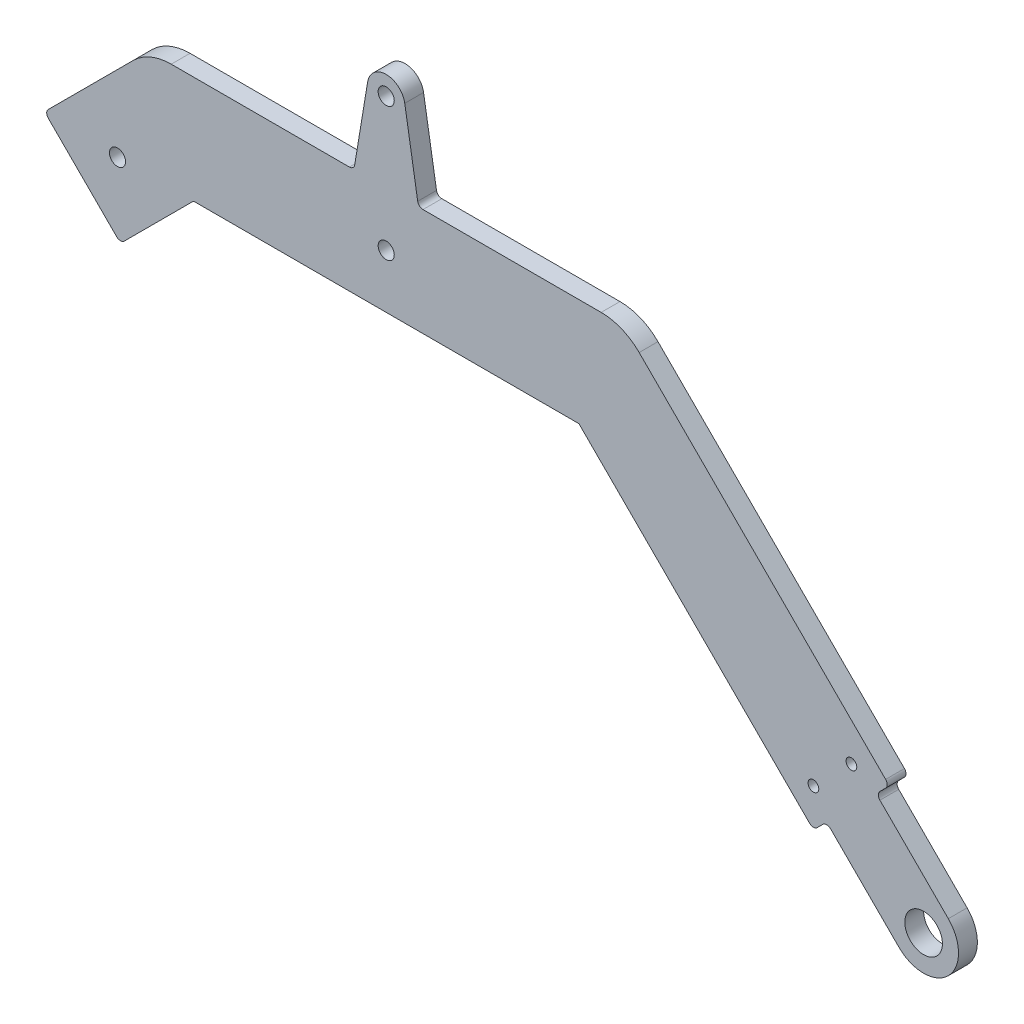
from build123d import *

# Parameters (mm, degrees)
SKETCH7_R           = 1.5
SKETCH7_R_2         = 3.5
SKETCH7_R_3         = 1
BOSS_EXTRUDE1_DEPTH = 3.5
FILLET8_R           = 10
FILLET14_R          = 1
FILLET15_R          = 1
FILLET16_R          = 1


with BuildPart() as part:
    # Sketch7 → Boss-Extrude1 (new body)
    with BuildSketch(Plane.XY):
        with BuildLine():
            Line((81.96877708, 8.838834765), (95.403805922, -4.596194078))
            ThreePointArc((95.403805922, -4.596194078), (104.596194078, -4.596194078), (104.596194078, 4.596194078))
            Line((104.596194078, 4.596194078), (91.161165235, 18.03122292))
            Line((91.161165235, 18.03122292), (93.636038969, 20.506096654))
            Line((93.636038969, 20.506096654), (44.142135624, 70))
            Line((44.142135624, 70), (6, 70))
            Line((6, 70), (3.453220204, 85.420324662))
            ThreePointArc((3.453220204, 85.420324662), (0, 88.35), (-3.453220204, 85.420324662))
            Line((-3.453220204, 85.420324662), (-6, 70))
            Line((-6, 70), (-44.142135624, 70))
            Line((-44.142135624, 70), (-63.587572106, 50.554563517))
            Line((-63.587572106, 50.554563517), (-49.445436483, 36.412427894))
            Line((-49.445436483, 36.412427894), (-35.857864376, 50))
            Line((-35.857864376, 50), (35.857864376, 50))
            Line((35.857864376, 50), (79.493903346, 6.363961031))
            Line((79.493903346, 6.363961031), (81.96877708, 8.838834765))
        make_face()
        with Locations((0, 84.85)):
            Circle(SKETCH7_R, mode=Mode.SUBTRACT)
        with Locations((0, 60)):
            Circle(SKETCH7_R, mode=Mode.SUBTRACT)
        with Locations((100, 0)):
            Circle(SKETCH7_R_2, mode=Mode.SUBTRACT)
        with Locations((86.564971157, 20.506096654)):
            Circle(SKETCH7_R_3, mode=Mode.SUBTRACT)
        with Locations((79.493903346, 13.435028843)):
            Circle(SKETCH7_R_3, mode=Mode.SUBTRACT)
        with Locations((-50, 50)):
            Circle(SKETCH7_R, mode=Mode.SUBTRACT)
    extrude(amount=BOSS_EXTRUDE1_DEPTH)

    # Fillet8
    fillet8_edges = [part.edges().sort_by_distance(p)[0] for p in [
        (-44.142135624, 70, 1.75),
        (44.142135624, 70, 1.75),
    ]]
    fillet(fillet8_edges, radius=FILLET8_R)

    # Fillet14
    fillet14_edges = [part.edges().sort_by_distance(p)[0] for p in [
        (93.636038969, 20.506096654, 1.75),
        (91.161165235, 18.03122292, 1.75),
    ]]
    fillet(fillet14_edges, radius=FILLET14_R)

    # Fillet15
    fillet15_edges = [part.edges().sort_by_distance(p)[0] for p in [
        (-49.445436483, 36.412427894, 1.75),
        (-63.587572106, 50.554563517, 1.75),
        (81.96877708, 8.838834765, 1.75),
        (79.493903346, 6.363961031, 1.75),
    ]]
    fillet(fillet15_edges, radius=FILLET15_R)

    # Fillet16
    fillet16_edges = [part.edges().sort_by_distance(p)[0] for p in [
        (-6, 70, 1.75),
        (6, 70, 1.75),
    ]]
    fillet(fillet16_edges, radius=FILLET16_R)


solid = part.part
